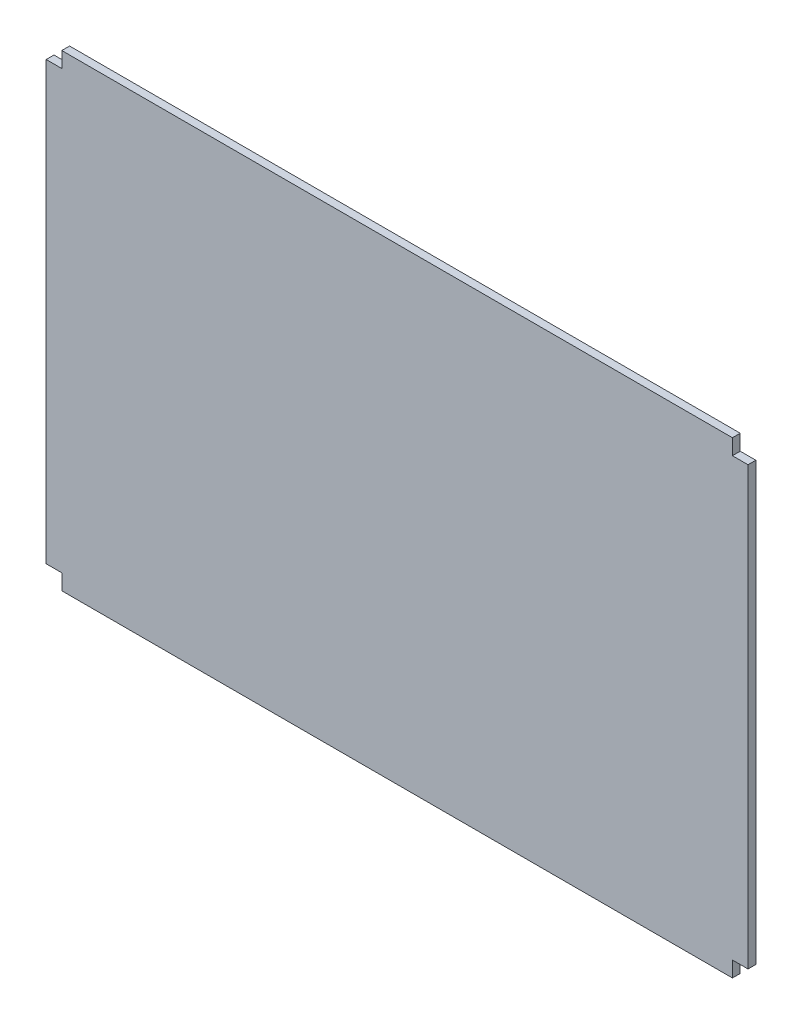
from build123d import *

# Parameters (mm, degrees)
SKETCH2_W           = 900
SKETCH2_H           = 600
BOSS_EXTRUDE1_DEPTH = 10
SKETCH3_W           = 20
SKETCH3_H           = 20
CUT_EXTRUDE1_DEPTH  = 11


with BuildPart() as part:
    # Sketch2 → Boss-Extrude1 (new body)
    with BuildSketch(Plane.XY):
        with Locations((450, 300)):
            Rectangle(SKETCH2_W, SKETCH2_H)
    extrude(amount=BOSS_EXTRUDE1_DEPTH)

    # Sketch3 → Cut-Extrude1 (cut, through all)
    with BuildSketch(Plane.XY.offset(10)):
        with Locations((10, 590)):
            Rectangle(SKETCH3_W, SKETCH3_H)
        with Locations((890, 590)):
            Rectangle(SKETCH3_W, SKETCH3_H)
        with Locations((890, 10)):
            Rectangle(SKETCH3_W, SKETCH3_H)
        with Locations((10, 10)):
            Rectangle(SKETCH3_W, SKETCH3_H)
    extrude(amount=-CUT_EXTRUDE1_DEPTH, mode=Mode.SUBTRACT)


solid = part.part
